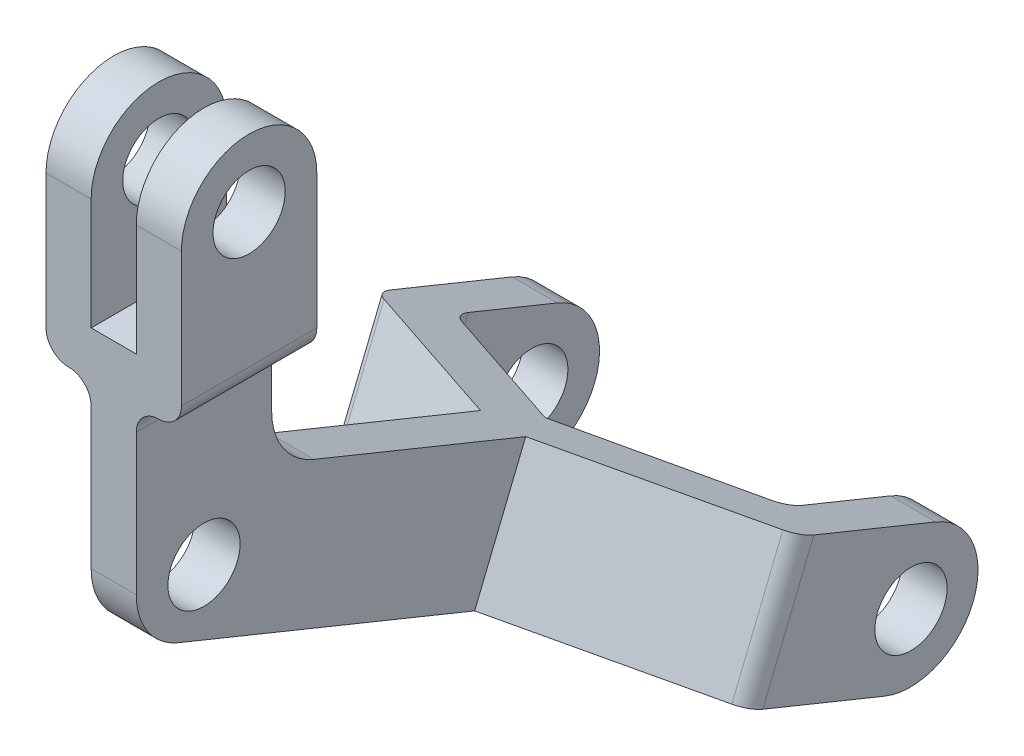
from build123d import *

# Parameters (mm, degrees)
SKETCH1_R           = 4
BOSS_EXTRUDE1_DEPTH = 5
BOSS_EXTRUDE2_DEPTH = 15
SKETCH3_R           = 7.5
SKETCH3_R_2         = 4
BOSS_EXTRUDE3_DEPTH = 5
SKETCH5_R           = 4
CUT_EXTRUDE1_DEPTH  = 5
SKETCH6_R           = 7.5
BOSS_EXTRUDE4_DEPTH = 5
SKETCH7_R           = 4
CUT_EXTRUDE2_DEPTH  = 5
BOSS_EXTRUDE5_DEPTH = 15
SKETCH9_R           = 7.5
BOSS_EXTRUDE6_DEPTH = 5
SKETCH10_R          = 7.5
BOSS_EXTRUDE7_DEPTH = 5
SKETCH11_R          = 4
CUT_EXTRUDE3_DEPTH  = 64


with BuildPart() as part:
    # Sketch1 → Boss-Extrude1 (new body)
    with BuildSketch(Plane(origin=(0, 0, 0), x_dir=(0, 0, -1), z_dir=(1, 0, 0))):
        with BuildLine():
            Line((15, 0), (0, 0))
            Line((0, 0), (0, -15.59))
            ThreePointArc((0, -15.59), (1.276909506, -19.776065539), (4.672838586, -22.536737244))
            Line((4.672838586, -22.536737244), (37.484806943, -35.890449582))
            Line((37.484806943, -35.890449582), (43.13912977, -21.996975093))
            Line((43.13912977, -21.996975093), (19.672838586, -12.446737244))
            ThreePointArc((19.672838586, -12.446737244), (16.276909506, -9.686065539), (15, -5.5))
            Line((15, -5.5), (15, 0))
        make_face()
        with Locations((7.5, -16.462434129)):
            Circle(SKETCH1_R, mode=Mode.SUBTRACT)
    extrude(amount=BOSS_EXTRUDE1_DEPTH)

    # Sketch2 → Boss-Extrude2 (add)
    with BuildSketch(Plane.XY):
        with BuildLine():
            Line((0, 0), (5, 0))
            ThreePointArc((5, 0), (5.732233047, 1.767766953), (7.5, 2.5))
            ThreePointArc((7.5, 2.5), (9.267766953, 3.232233047), (10, 5))
            Line((10, 5), (10, 19.86))
            Line((10, 19.86), (5, 19.86))
            Line((5, 19.86), (5, 7.5))
            Line((5, 7.5), (0, 7.5))
            Line((0, 7.5), (0, 19.86))
            Line((0, 19.86), (-5, 19.86))
            Line((-5, 19.86), (-5, 5))
            ThreePointArc((-5, 5), (-4.267766953, 3.232233047), (-2.5, 2.5))
            ThreePointArc((-2.5, 2.5), (-0.732233047, 1.767766953), (0, 0))
        make_face()
    extrude(amount=-BOSS_EXTRUDE2_DEPTH)

    # Sketch3 → Boss-Extrude3 (add)
    with BuildSketch(Plane(origin=(10, 0, 0), x_dir=(0, 0, -1), z_dir=(1, 0, 0))):
        with Locations((7.5, 19.86)):
            Circle(SKETCH3_R)
        with Locations((7.5, 19.86)):
            Circle(SKETCH3_R_2, mode=Mode.SUBTRACT)
    extrude(amount=-BOSS_EXTRUDE3_DEPTH)

    # Sketch5 → Cut-Extrude1 (cut)
    with BuildSketch(Plane(origin=(10, 0, 0), x_dir=(0, 0, -1), z_dir=(1, 0, 0))):
        with Locations((7.5, 19.86)):
            Circle(SKETCH5_R)
    extrude(amount=-CUT_EXTRUDE1_DEPTH, mode=Mode.SUBTRACT)

    # Sketch6 → Boss-Extrude4 (add)
    with BuildSketch(Plane.ZY.offset(5)):
        with Locations((-7.5, 19.86)):
            Circle(SKETCH6_R)
    extrude(amount=-BOSS_EXTRUDE4_DEPTH)

    # Sketch7 → Cut-Extrude2 (cut)
    with BuildSketch(Plane.ZY.offset(5)):
        with Locations((-7.5, 19.86)):
            Circle(SKETCH7_R)
    extrude(amount=-CUT_EXTRUDE2_DEPTH, mode=Mode.SUBTRACT)

    # Sketch8 → Boss-Extrude5 (add)
    with BuildSketch(Plane(origin=(0, -3.809395954, 1.55033606), x_dir=(1, 0, 0), z_dir=(0, 0.926231633, -0.376954855))):
        with BuildLine():
            Line((0, 48.248693155), (5, 48.248693155))
            Line((5, 48.248693155), (24.55634321, 57.895622609))
            ThreePointArc((24.55634321, 57.895622609), (25.552769913, 58.816883816), (25.92108759, 60.122996551))
            Line((25.92108759, 60.122996551), (25.92108759, 74.712996551))
            Line((25.92108759, 74.712996551), (20.92108759, 74.712996551))
            Line((20.92108759, 74.712996551), (20.92108759, 64.128787942))
            ThreePointArc((20.92108759, 64.128787942), (20.552769913, 62.822675208), (19.55634321, 61.901414001))
            Line((19.55634321, 61.901414001), (2.258260879, 53.528693155))
            Line((2.258260879, 53.528693155), (-14.685235236, 61.886733815))
            ThreePointArc((-14.685235236, 61.886733815), (-15.702336235, 62.808740922), (-16.079254544, 64.128787942))
            Line((-16.079254544, 64.128787942), (-16.079254544, 74.791257758))
            Line((-16.079254544, 74.791257758), (-21.079254544, 74.791257758))
            Line((-21.079254544, 74.791257758), (-21.079254544, 60.201257758))
            ThreePointArc((-21.079254544, 60.201257758), (-20.702336235, 58.881210738), (-19.685235236, 57.95920363))
            Line((-19.685235236, 57.95920363), (0, 48.248693155))
        make_face()
    extrude(amount=-BOSS_EXTRUDE5_DEPTH)

    # Sketch9 → Boss-Extrude6 (add)
    with BuildSketch(Plane(origin=(25.92108759, 0, 0), x_dir=(0, 0, -1), z_dir=(1, 0, 0))):
        with Locations((64.824043295, -38.919559991)):
            Circle(SKETCH9_R)
    extrude(amount=-BOSS_EXTRUDE6_DEPTH)

    # Sketch10 → Boss-Extrude7 (add)
    with BuildSketch(Plane.ZY.offset(21.079254544)):
        with Locations((-64.896531301, -38.949060933)):
            Circle(SKETCH10_R)
    extrude(amount=-BOSS_EXTRUDE7_DEPTH)

    # Sketch11 → Cut-Extrude3 (cut)
    with BuildSketch(Plane(origin=(25.92108759, 0, 0), x_dir=(0, 0, -1), z_dir=(1, 0, 0))):
        with Locations((64.896531301, -38.949060933)):
            Circle(SKETCH11_R)
    extrude(amount=-CUT_EXTRUDE3_DEPTH, mode=Mode.SUBTRACT)


solid = part.part
